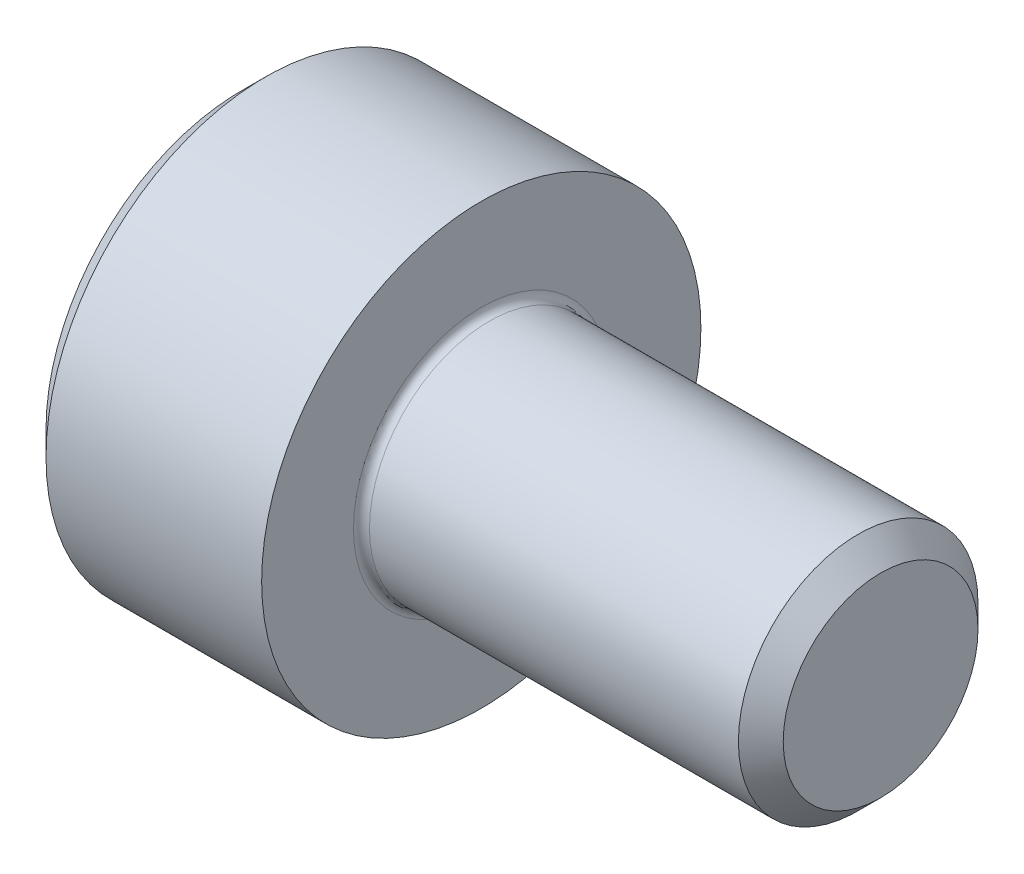
from build123d import *

# Parameters (mm, degrees)
FILLET1_R   = 0.1
HEX_2_DEPTH = 1.3


with BuildPart() as part:
    # BodySke → Base-Revolve (revolve)
    with BuildSketch(Plane.XY):
        Polygon((0, 0), (0, 2.45), (0.3, 2.75), (3, 2.75), (3, 1.5), (7.7195, 1.5), (8, 1.2195), (8, 0), align=None)
    revolve(axis=Axis((-31.75, 0, 0), (1, 0, 0)))

    # Fillet1
    fillet1_edges = [part.edges().sort_by_distance(p)[0] for p in [
        (3, -1.5, 0),
    ]]
    fillet(fillet1_edges, radius=FILLET1_R)

    # Sketch2 → Hex-PreBroach (revolve, cut)
    with BuildSketch(Plane.XY):
        Polygon((0, 1.28), (1.3, 1.28), (2.039008345, 0), (0, 0), align=None)
    revolve(axis=Axis((0, 0, 0), (1, 0, 0)), mode=Mode.SUBTRACT)

    # Sketch3 → Hex 2 (cut)
    with BuildSketch(Plane(origin=(0, 0, 0), x_dir=(0, 0.5, 0.866025404), z_dir=(-1, 0, 0))):
        Polygon((0.739008345, 1.28), (-0.739008345, 1.28), (-1.478016689, 0), (-0.739008345, -1.28), (0.739008345, -1.28), (1.478016689, 0), align=None)
    extrude(amount=-HEX_2_DEPTH, mode=Mode.SUBTRACT)


solid = part.part
